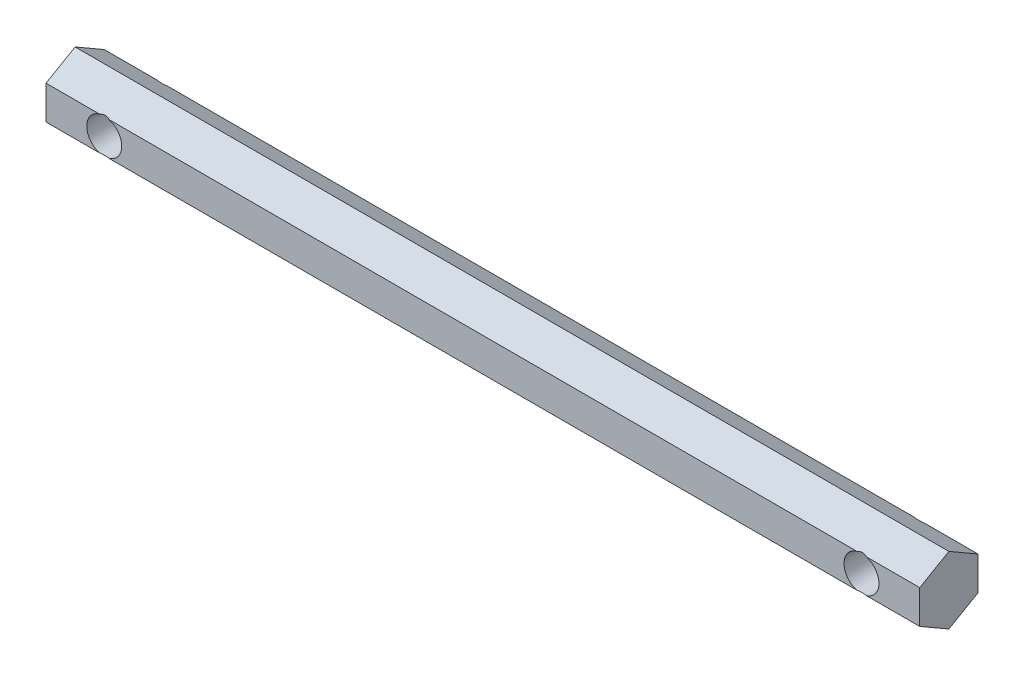
from build123d import *

# Parameters (mm, degrees)
BOSS_EXTRUDE1_DEPTH     = 75
SKETCH2_R               = 3
CUT_EXTRUDE1_DEPTH      = 6
CUT_EXTRUDE1_DEPTH_BACK = 6


with BuildPart() as part:
    # Sketch1 → Boss-Extrude1 (new body, symmetric)
    with BuildSketch(Plane(origin=(0, 0, 0), x_dir=(0, 0, -1), z_dir=(1, 0, 0))):
        Polygon((0, 5.773502692), (-5, 2.886751346), (-5, -2.886751346), (0, -5.773502692), (5, -2.886751346), (5, 2.886751346), align=None)
    extrude(amount=BOSS_EXTRUDE1_DEPTH, both=True)

    # Sketch2 → Cut-Extrude1 (cut, two sides)
    with BuildSketch(Plane.XY) as cut_extrude1_sk:
        with Locations((65, 0)):
            Circle(SKETCH2_R)
        with Locations((-65, 0)):
            Circle(SKETCH2_R)
    extrude(amount=CUT_EXTRUDE1_DEPTH, mode=Mode.SUBTRACT)
    extrude(cut_extrude1_sk.sketch, amount=-CUT_EXTRUDE1_DEPTH_BACK, mode=Mode.SUBTRACT)


solid = part.part
